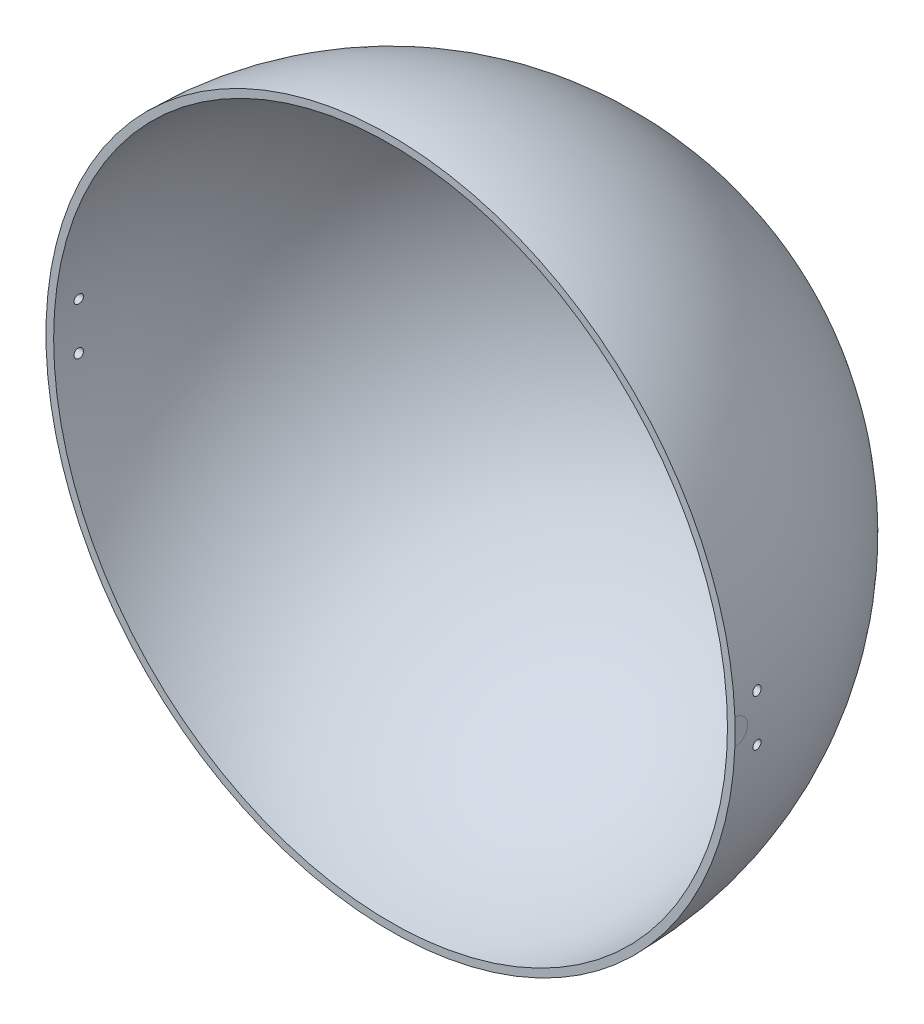
from build123d import *

# Parameters (mm, degrees)
SKETCH_3_R          = 1.75
CUT_EXTRUDE_2_DEPTH = 211.5
SKETCH_4_R          = 5
CUT_EXTRUDE_3_DEPTH = 0.1


with BuildPart() as part:
    # Эскиз2 → Повернуть1 (revolve)
    with BuildSketch(Plane(origin=(0, 0, 0), x_dir=(1, 0, 0), z_dir=(0, 1, 0))):
        with BuildLine():
            Line((-135, 0), (-132, 0))
            ThreePointArc((-132, 0), (-93.338095117, 93.338095117), (0, 132))
            Line((0, 132), (0, 135))
            ThreePointArc((0, 135), (-95.45941546, 95.45941546), (-135, 0))
        make_face()
    revolve(axis=Axis((0, 0, -135), (0, 0, 1)))

    # Эскиз3 → Вырез-Вытянуть2 (cut, symmetric)
    with BuildSketch(Plane(origin=(0, 0, 0), x_dir=(0, -1, 0), z_dir=(1, 0, 0))):
        with Locations((9.192388155, 9.192388155)):
            Circle(SKETCH_3_R)
        with Locations((-9.192388155, 9.192388155)):
            Circle(SKETCH_3_R)
    extrude(amount=CUT_EXTRUDE_2_DEPTH, both=True, mode=Mode.SUBTRACT)

    # Эскиз4 → Вырез-Вытянуть3 (cut)
    with BuildSketch(Plane(origin=(135, 0, 0), x_dir=(0, 0, -1), z_dir=(1, 0, 0))):
        Circle(SKETCH_4_R)
    cut_extrude_3 = extrude(amount=-CUT_EXTRUDE_3_DEPTH, mode=Mode.SUBTRACT)

    # Зеркальное отражение1: Вырез-Вытянуть3 across plane
    add(cut_extrude_3.mirror(Plane(origin=(0, 0, 0), x_dir=(0, 0, 1), z_dir=(1, 0, 0))), mode=Mode.SUBTRACT)


solid = part.part
